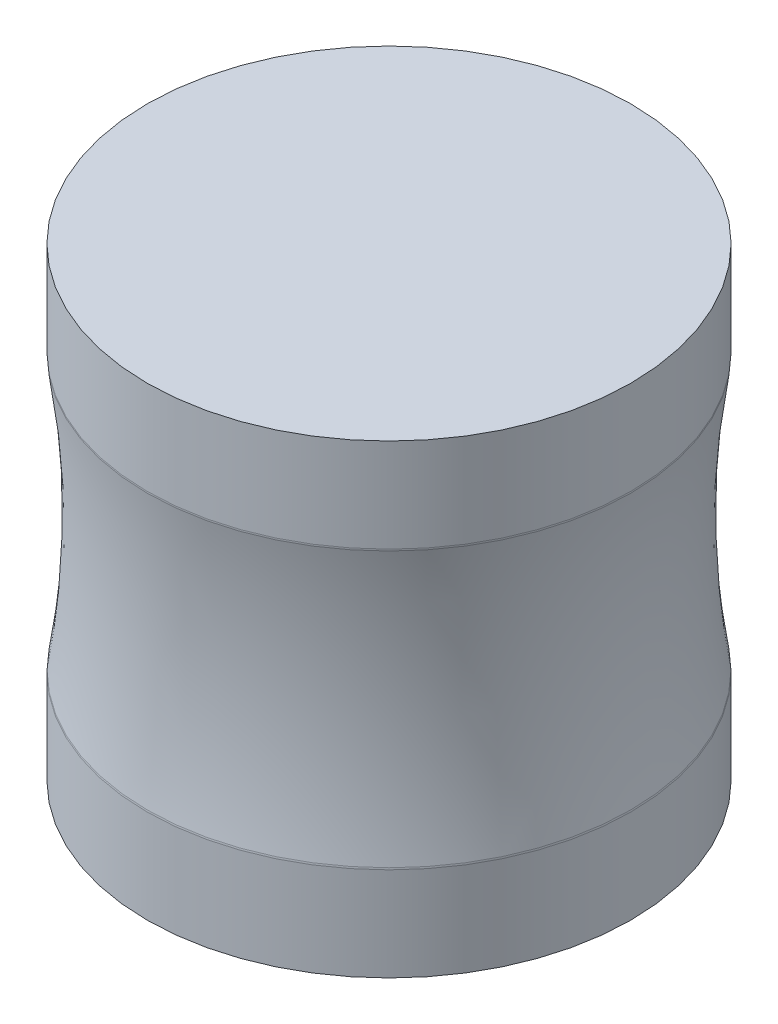
from build123d import *


with BuildPart() as part:
    # Skizze1 → Rotation1 (revolve)
    with BuildSketch(Plane.XY, mode=Mode.PRIVATE) as rotation1_sk:
        with BuildLine():
            Line((109.527295839, -62.872686635), (109.527295839, -105.259657321))
            Line((109.527295839, -105.259657321), (0, -105.259657321))
            Line((0, -105.259657321), (0, 105.259657321))
            Line((0, 105.259657321), (109.527295839, 105.259657321))
            Line((109.527295839, 105.259657321), (109.527295839, 62.872686635))
            ThreePointArc((109.527295839, 62.872686635), (109.511559563, 62.47630913), (109.464449789, 62.082426628))
            ThreePointArc((109.464449789, 62.082426628), (104.527295839, 0), (109.464449789, -62.082426628))
            ThreePointArc((109.464449789, -62.082426628), (109.511559563, -62.47630913), (109.527295839, -62.872686635))
        make_face()
    revolve(rotation1_sk.sketch.rotate(Axis((0, 105.259657321, 0), (0, -1, 0)), 90), axis=Axis((0, 105.259657321, 0), (0, -1, 0)))  # turned: the seam where the file's is


solid = part.part
